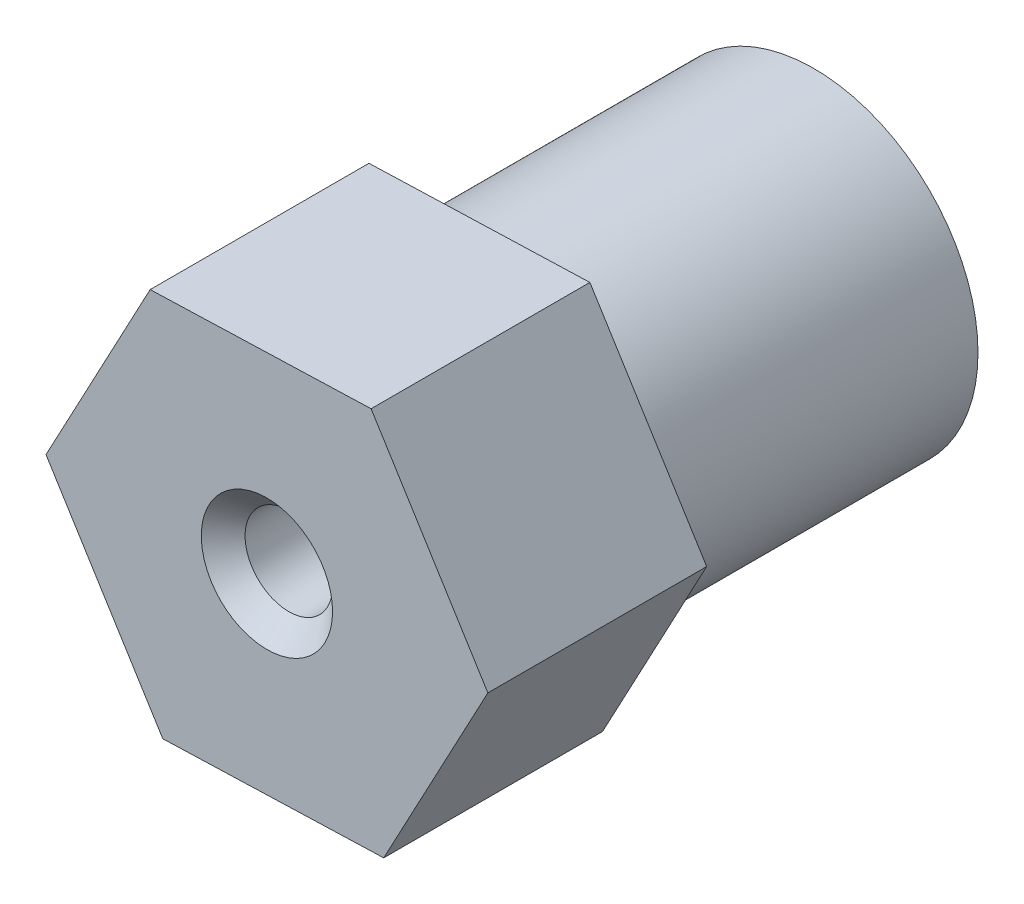
from build123d import *

# Parameters (mm, degrees)
SKETCH1_R           = 4.7625
SKETCH1_R_2         = 2.54
BOSS_EXTRUDE1_DEPTH = 9.525
BOSS_EXTRUDE2_DEPTH = 6.35
CUT_EXTRUDE1_REACH  = 17.875
SKETCH3_R           = 1.27
CHAMFER1_SIZE       = 0.635


with BuildPart() as part:
    # Sketch1 → Boss-Extrude1 (new body)
    with BuildSketch(Plane.XY):
        Circle(SKETCH1_R)
        Circle(SKETCH1_R_2, mode=Mode.SUBTRACT)
    extrude(amount=BOSS_EXTRUDE1_DEPTH)

    # Sketch2 → Boss-Extrude2 (add)
    with BuildSketch(Plane.XY.offset(9.525)):
        Polygon((3.022954056, 5.659001754), (-3.389362251, 5.447455885), (-6.412316308, -0.21154587), (-3.022954056, -5.659001754), (3.389362251, -5.447455885), (6.412316308, 0.21154587), align=None)
    extrude(amount=BOSS_EXTRUDE2_DEPTH)

    # Sketch3 → Cut-Extrude1 (cut, up to next)
    with BuildSketch(Plane.XY.offset(15.875), mode=Mode.PRIVATE) as cut_extrude1_sk1:
        Circle(SKETCH3_R)
    cut_extrude1_tool1 = extrude(cut_extrude1_sk1.sketch, amount=-CUT_EXTRUDE1_REACH, mode=Mode.PRIVATE) & part.part
    add(cut_extrude1_tool1.solids().sort_by_distance((0, 0, 15.875))[0], mode=Mode.SUBTRACT)

    # Chamfer1
    chamfer1_edges = [part.edges().sort_by_distance(p)[0] for p in [
        (-1.27, 0, 15.875),
    ]]
    chamfer(chamfer1_edges, length=CHAMFER1_SIZE)


solid = part.part
